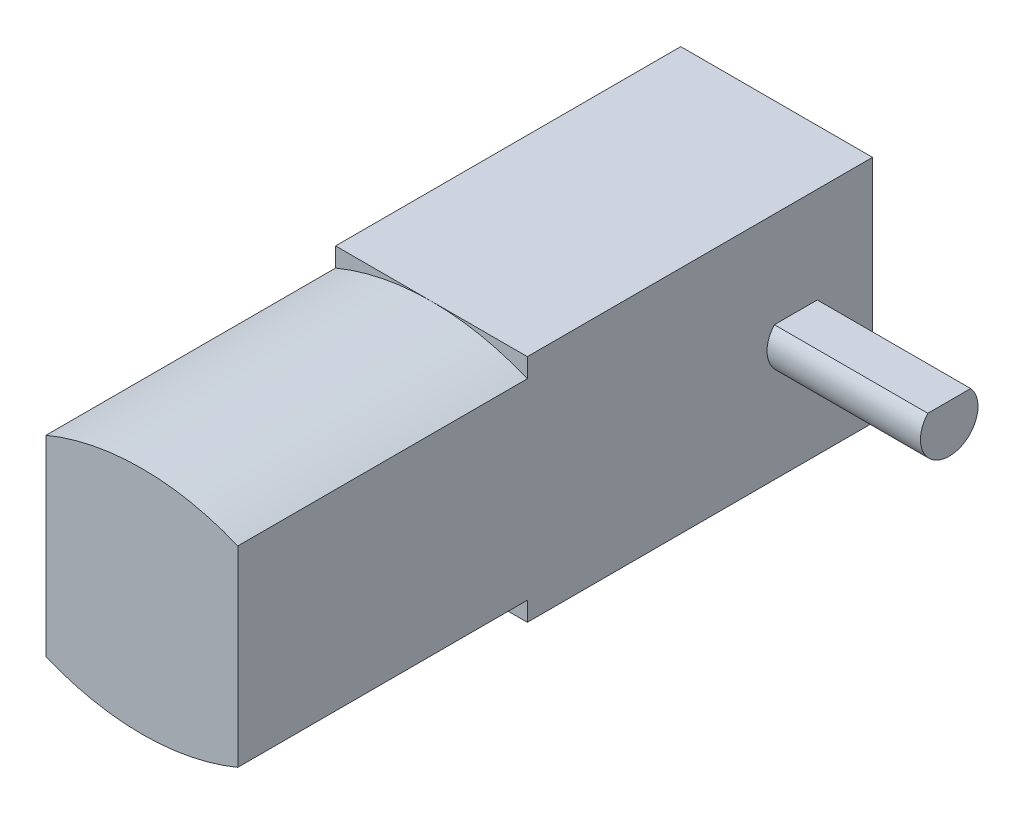
from build123d import *

# Parameters (mm, degrees)
SKETCH1_W           = 5
SKETCH1_H           = 10
BOSS_EXTRUDE1_DEPTH = 15.1
SKETCH2_W           = 10
SKETCH2_H           = 12
BOSS_EXTRUDE2_DEPTH = 18
BOSS_EXTRUDE3_DEPTH = 8


with BuildPart() as part:
    # Sketch1 → Boss-Extrude1 (new body)
    with BuildSketch(Plane.XY):
        with Locations((-2.5, 0)):
            Rectangle(SKETCH1_W, SKETCH1_H)
        with Locations((2.5, 0)):
            Rectangle(SKETCH1_W, SKETCH1_H)
        with BuildLine():
            Line((0, 6), (0, 5))
            Line((0, 5), (5, 5))
            ThreePointArc((5, 5), (2.549509757, 5.747548784), (0, 6))
        make_face()
        with BuildLine():
            Line((-5, 5), (0, 5))
            Line((0, 5), (0, 6))
            ThreePointArc((0, 6), (-2.549509757, 5.747548784), (-5, 5))
        make_face()
        with BuildLine():
            Line((0, -5), (0, -6))
            ThreePointArc((0, -6), (2.549509757, -5.747548784), (5, -5))
            Line((5, -5), (0, -5))
        make_face()
        with BuildLine():
            ThreePointArc((-5, -5), (-2.549509757, -5.747548784), (0, -6))
            Line((0, -6), (0, -5))
            Line((0, -5), (-5, -5))
        make_face()
    extrude(amount=BOSS_EXTRUDE1_DEPTH)

    # Sketch2 → Boss-Extrude2 (add)
    with BuildSketch(Plane.XY):
        Rectangle(SKETCH2_W, SKETCH2_H)
    extrude(amount=-BOSS_EXTRUDE2_DEPTH)

    # Sketch3 → Boss-Extrude3 (add)
    with BuildSketch(Plane(origin=(5, 0, 0), x_dir=(0, 0, -1), z_dir=(1, 0, 0))):
        with BuildLine():
            Line((14, -1.5), (14, 0))
            Line((14, 0), (14, 1))
            Line((14, 1), (12.881966011, 1))
            ThreePointArc((12.881966011, 1), (12.630693606, -0.612372436), (14, -1.5))
        make_face()
        with BuildLine():
            Line((14, 0), (15.5, 0))
            ThreePointArc((15.5, 0), (15.401258538, 0.535233135), (15.118033989, 1))
            Line((15.118033989, 1), (14, 1))
            Line((14, 1), (14, 0))
        make_face()
        with BuildLine():
            ThreePointArc((14, -1.5), (15.060660172, -1.060660172), (15.5, 0))
            Line((15.5, 0), (14, 0))
            Line((14, 0), (14, -1.5))
        make_face()
    extrude(amount=BOSS_EXTRUDE3_DEPTH)


solid = part.part
